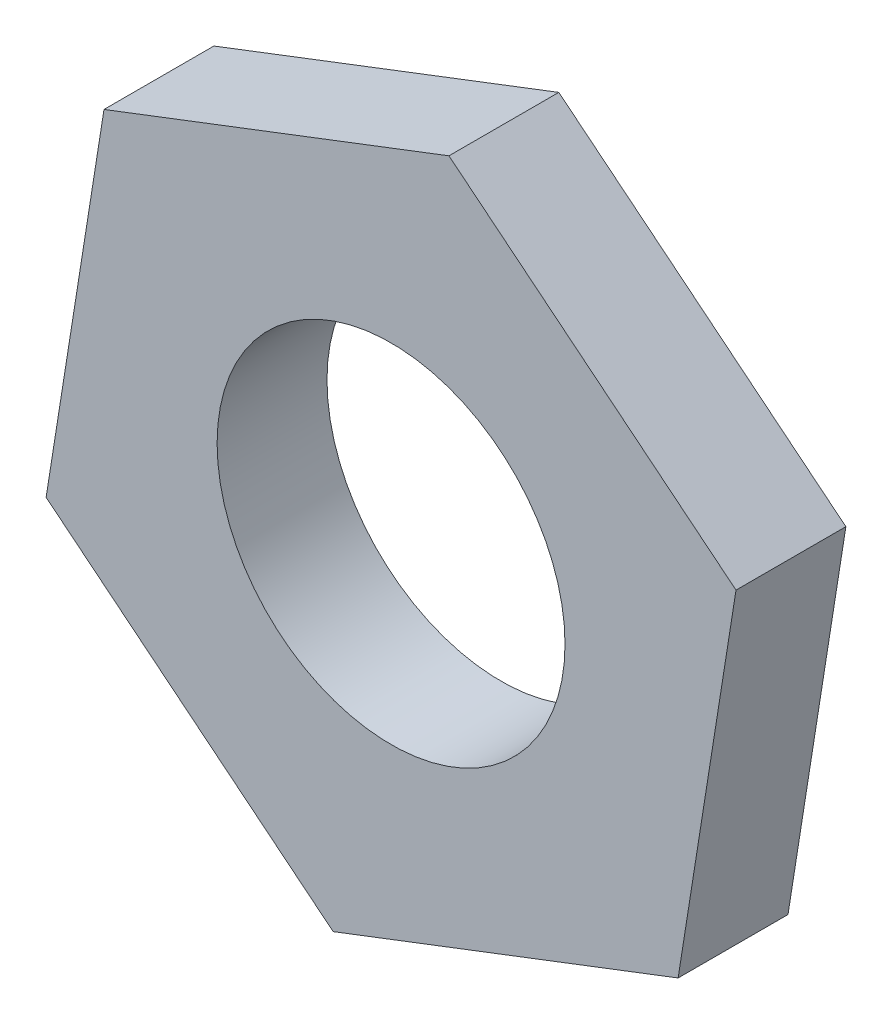
from build123d import *

# Parameters (mm, degrees)
CROQUIS1_R              = 4.75
SALIENTE_EXTRUIR1_DEPTH = 3


with BuildPart() as part:
    # Croquis1 → Saliente-Extruir1 (new body)
    with BuildSketch(Plane.XY):
        Polygon((7.837916431, -6.350353377), (9.418525563, 3.612658053), (1.580609132, 9.96301143), (-7.837916431, 6.350353377), (-9.418525563, -3.612658053), (-1.580609132, -9.96301143), align=None)
        Circle(CROQUIS1_R, mode=Mode.SUBTRACT)
    extrude(amount=SALIENTE_EXTRUIR1_DEPTH)


solid = part.part
